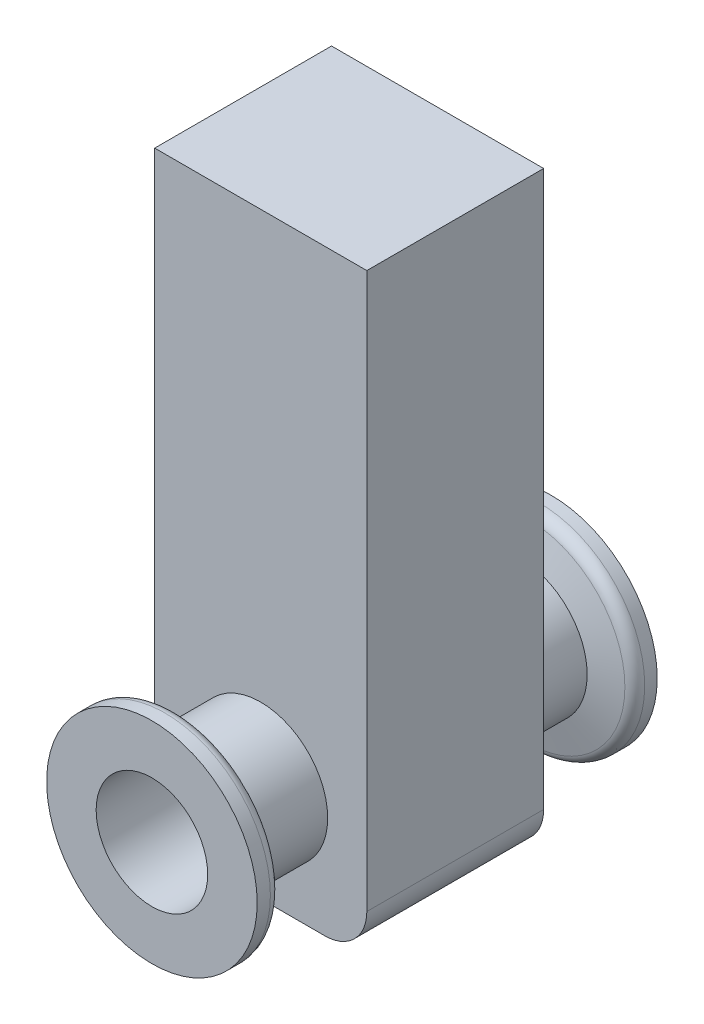
from build123d import *

# Parameters (mm, degrees)
BOSS_EXTRUDE1_DEPTH = 25.1714


with BuildPart() as part:
    # Sketch1 → Boss-Extrude1 (new body)
    with BuildSketch(Plane.XY.offset(12.5857)):
        with BuildLine():
            Line((-15.096819971, 70.27139515), (-15.096819971, -8.74510913))
            ThreePointArc((-15.096819971, -8.74510913), (-13.34429465, -12.976079529), (-9.113324251, -14.72860485))
            Line((-9.113324251, -14.72860485), (9.113324251, -14.72860485))
            ThreePointArc((9.113324251, -14.72860485), (13.34429465, -12.976079529), (15.096819971, -8.74510913))
            Line((15.096819971, -8.74510913), (15.096819971, 70.27139515))
            Line((15.096819971, 70.27139515), (-15.096819971, 70.27139515))
        make_face()
    extrude(amount=-BOSS_EXTRUDE1_DEPTH)

    # Sketch2 → Revolve1 (revolve)
    with BuildSketch(Plane(origin=(0, 0, 0), x_dir=(1, 0, 0), z_dir=(0, 1, 0))):
        with BuildLine():
            Line((15.767676296, 28.0797), (0.740743286, 28.0797))
            Line((0.740743286, 28.0797), (0.740743286, 12.5857))
            Line((0.740743286, 12.5857), (10.306676296, 12.5857))
            Line((10.306676296, 12.5857), (10.306676296, 23.56842946))
            Line((10.306676296, 23.56842946), (14.543986539, 24.703813318))
            ThreePointArc((14.543986539, 24.703813318), (15.426502661, 25.293491738), (15.767676296, 26.298556857))
            Line((15.767676296, 26.298556857), (15.767676296, 28.0797))
        make_face()
    revolve(axis=Axis((0.740743286, 0, -28.0797), (0, 0, 1)))

    # Sketch3 → Revolve2 (revolve)
    with BuildSketch(Plane(origin=(0, 0, 0), x_dir=(1, 0, 0), z_dir=(0, 1, 0))):
        with BuildLine():
            Line((9.525, -12.5857), (0, -12.5857))
            Line((0, -12.5857), (0, -28.0797))
            Line((0, -28.0797), (14.986, -28.0797))
            Line((14.986, -28.0797), (14.986, -26.20110633))
            ThreePointArc((14.986, -26.20110633), (14.671070491, -25.273353912), (13.856440225, -24.72903537))
            Line((13.856440225, -24.72903537), (9.525, -23.56842946))
            Line((9.525, -23.56842946), (9.525, -12.5857))
        make_face()
    revolve(axis=Axis((0, 0, 3.0607), (0, 0, 1)))

    # Sketch4 → Cut-Revolve1 (revolve, cut)
    with BuildSketch(Plane.XZ):
        Polygon((8.636, 37.6047), (0, 37.6047), (0, -37.6047), (8.636, -37.6047), (8.636, -35.0647), (7.9375, -35.0647), (7.9375, 35.0647), (8.636, 35.0647), align=None)
    revolve(axis=Axis((0, 0, 37.6047), (0, 0, -1)), mode=Mode.SUBTRACT)


solid = part.part
